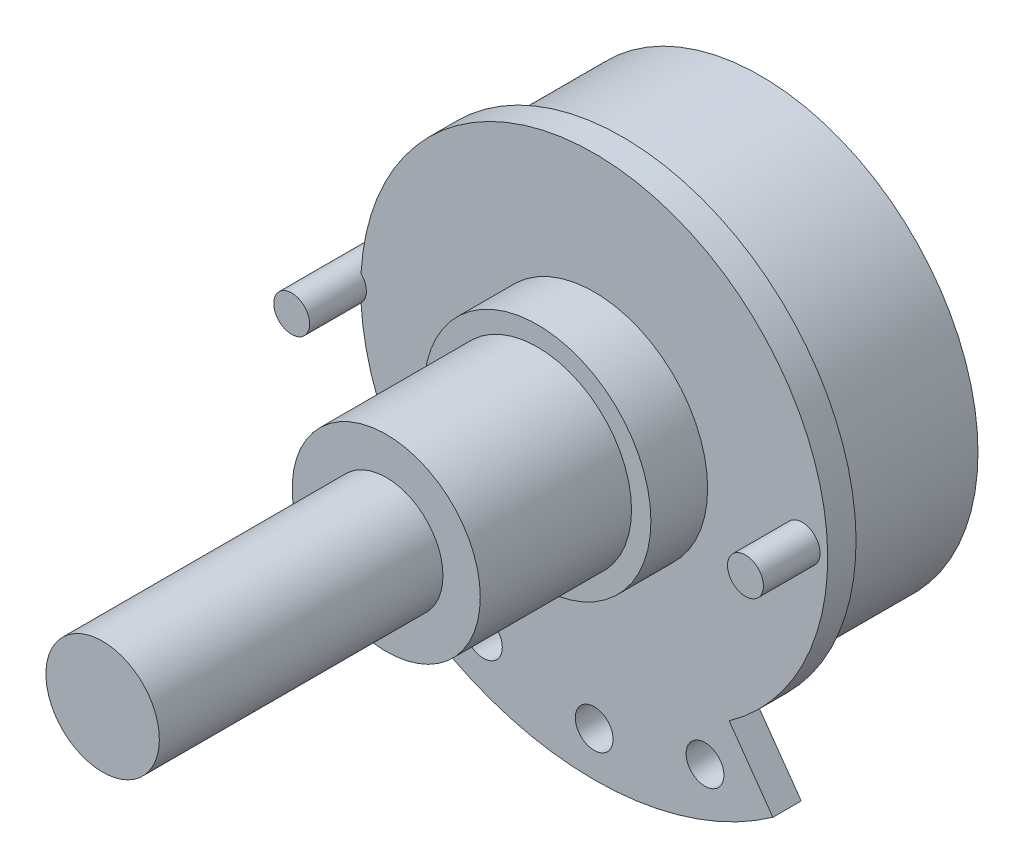
from build123d import *

# Parameters (mm, degrees)
SKETCH1_R      = 11.5
EXTRUDE1_DEPTH = 7.3
EXTRUDE2_DEPTH = 1.5
SKETCH3_R      = 1
EXTRUDE3_DEPTH = 1.5
SKETCH4_R      = 6
EXTRUDE4_DEPTH = 3
SKETCH5_R      = 4.975
EXTRUDE5_DEPTH = 8
SKETCH6_R      = 3
EXTRUDE6_DEPTH = 15
EXTRUDE7_START = -1.5
SKETCH7_R      = 0.95
EXTRUDE7_DEPTH = 4.5


with BuildPart() as part:
    # Sketch1 → Extrude1 (new body)
    with BuildSketch(Plane.XY):
        Circle(SKETCH1_R)
    extrude(amount=EXTRUDE1_DEPTH)

    # Sketch2 → Extrude2 (add)
    with BuildSketch(Plane.XY.offset(7.3)):
        with BuildLine():
            Line((-9.45, -13.342413575), (-7.138073394, -10.078214535))
            ThreePointArc((-7.138073394, -10.078214535), (0, 12.35), (7.138073394, -10.078214535))
            Line((7.138073394, -10.078214535), (9.45, -13.342413575))
            ThreePointArc((9.45, -13.342413575), (0, -16.35), (-9.45, -13.342413575))
        make_face()
    extrude(amount=EXTRUDE2_DEPTH)

    # Sketch3 → Extrude3 (cut)
    with BuildSketch(Plane.XY.offset(8.8)):
        with Locations((0, -14)):
            Circle(SKETCH3_R)
        with Locations((5.860626142, -12.714285714)):
            Circle(SKETCH3_R)
        with Locations((-5.860626142, -12.714285714)):
            Circle(SKETCH3_R)
    extrude(amount=-EXTRUDE3_DEPTH, mode=Mode.SUBTRACT)

    # Sketch4 → Extrude4 (add)
    with BuildSketch(Plane.XY.offset(8.8)):
        Circle(SKETCH4_R)
    extrude(amount=EXTRUDE4_DEPTH)

    # Sketch5 → Extrude5 (add)
    with BuildSketch(Plane.XY.offset(11.8)):
        Circle(SKETCH5_R)
    extrude(amount=EXTRUDE5_DEPTH)

    # Sketch6 → Extrude6 (add)
    with BuildSketch(Plane.XY.offset(19.8)):
        Circle(SKETCH6_R)
    extrude(amount=EXTRUDE6_DEPTH)

    # Sketch7 → Extrude7 (add)
    with BuildSketch(Plane.XY.offset(8.8).offset(EXTRUDE7_START)):
        with Locations((11, 0)):
            Circle(SKETCH7_R)
        with Locations((-13, 0)):
            Circle(SKETCH7_R)
    extrude(amount=EXTRUDE7_DEPTH)


solid = part.part
